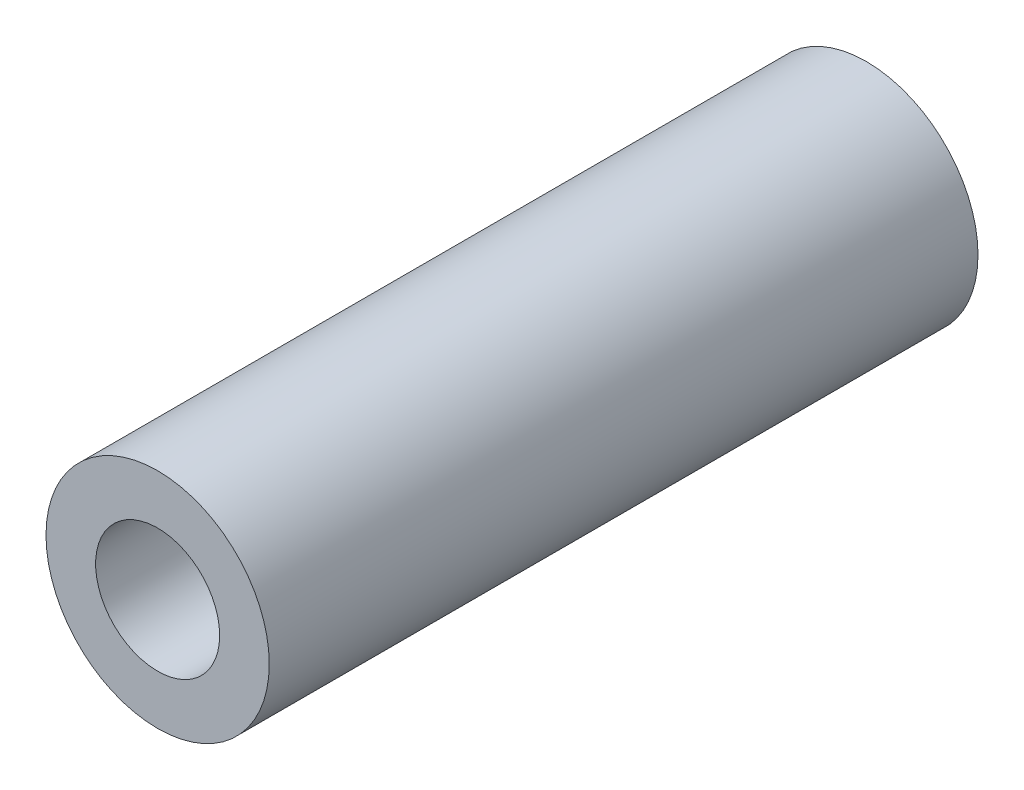
from build123d import *

# Parameters (mm, degrees)
SZKIC1_R                    = 3.15
SZKIC1_R_2                  = 1.75
DODANIE_WYCI_GNI_CIE1_DEPTH = 20


with BuildPart() as part:
    # Szkic1 → Dodanie-wyciągnięcie1 (new body)
    with BuildSketch(Plane.XY):
        Circle(SZKIC1_R)
        Circle(SZKIC1_R_2, mode=Mode.SUBTRACT)
    extrude(amount=DODANIE_WYCI_GNI_CIE1_DEPTH)


solid = part.part
